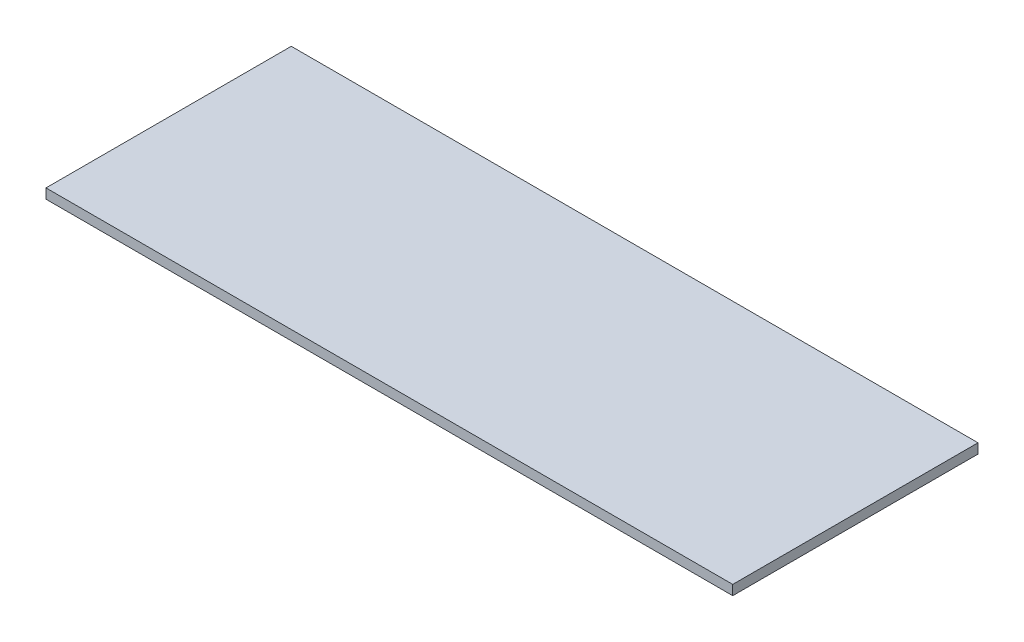
from build123d import *

# Parameters (mm, degrees)
SKETCH1_W           = 70
SKETCH1_H           = 25
BOSS_EXTRUDE1_DEPTH = 1


with BuildPart() as part:
    # Sketch1 → Boss-Extrude1 (new body)
    with BuildSketch(Plane(origin=(0, 0, 0), x_dir=(1, 0, 0), z_dir=(0, 1, 0))):
        with Locations((10.514403292, -4.495884774)):
            Rectangle(SKETCH1_W, SKETCH1_H)
    extrude(amount=BOSS_EXTRUDE1_DEPTH)


solid = part.part
